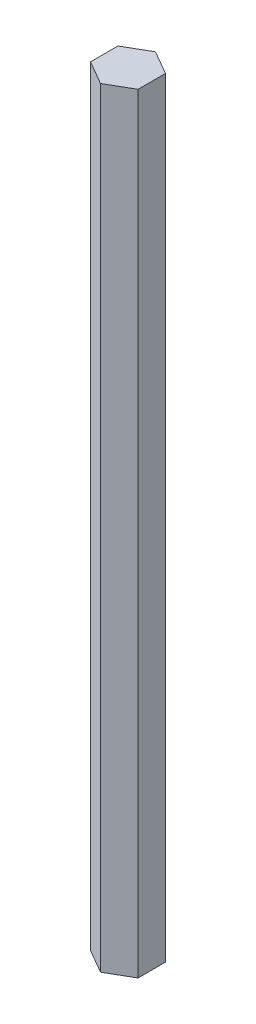
from build123d import *

# Parameters (mm, degrees)
BOSS_EXTRUDE1_DEPTH = 170.92422


with BuildPart() as part:
    # Sketch1 → Boss-Extrude1 (new body)
    with BuildSketch(Plane(origin=(0, 0, 0), x_dir=(1, 0, 0), z_dir=(0, 1, 0))):
        Polygon((-5.279290861, -3.048), (0, -6.096), (5.279290861, -3.048), (5.279290861, 3.048), (0, 6.096), (-5.279290861, 3.048), align=None)
    extrude(amount=BOSS_EXTRUDE1_DEPTH)


solid = part.part
